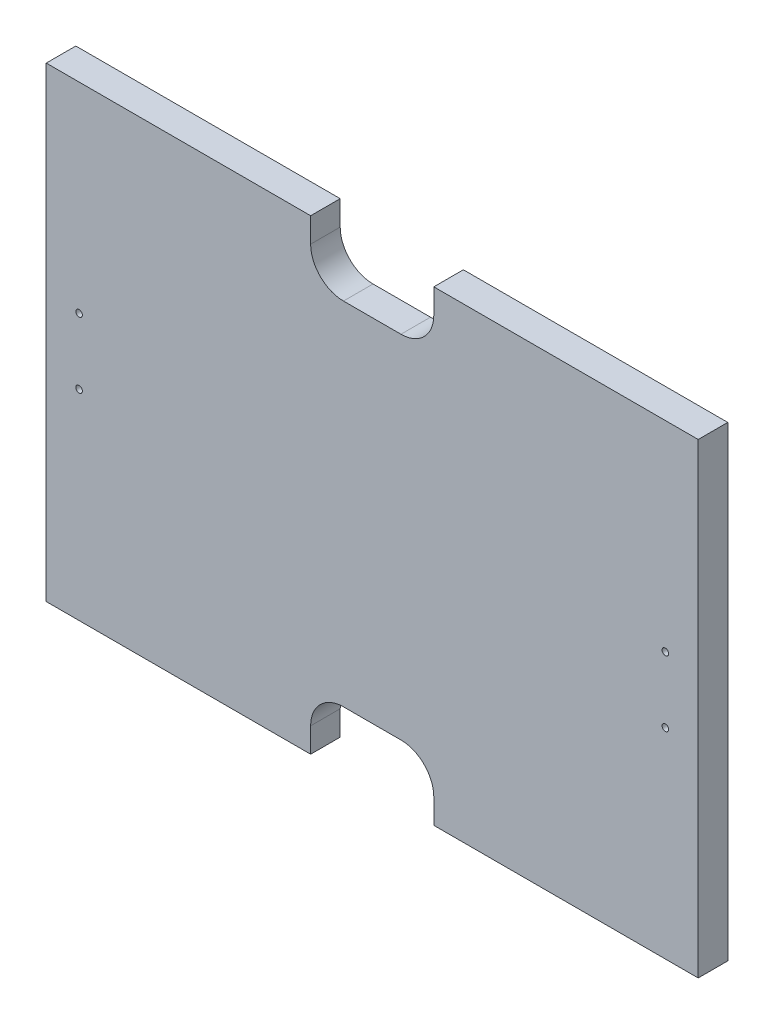
from build123d import *

# Parameters (mm, degrees)
SKETCH1_W           = 397
SKETCH1_H           = 284
BOSS_EXTRUDE1_DEPTH = 18
SKETCH2_R           = 2
CUT_EXTRUDE1_DEPTH  = 19


with BuildPart() as part:
    # Sketch1 → Boss-Extrude1 (new body)
    with BuildSketch(Plane.XY):
        with Locations((198.5, 142)):
            Rectangle(SKETCH1_W, SKETCH1_H)
    extrude(amount=BOSS_EXTRUDE1_DEPTH)

    # Sketch2 → Cut-Extrude1 (cut, through all)
    with BuildSketch(Plane.XY.offset(18)):
        with Locations((20, 162)):
            Circle(SKETCH2_R)
        with Locations((20, 122)):
            Circle(SKETCH2_R)
        with Locations((377, 122)):
            Circle(SKETCH2_R)
        with Locations((377, 162)):
            Circle(SKETCH2_R)
        with BuildLine():
            Line((236, 284), (161, 284))
            Line((161, 284), (161, 269))
            ThreePointArc((161, 269), (166.857864376, 254.857864376), (181, 249))
            Line((181, 249), (216, 249))
            ThreePointArc((216, 249), (230.142135624, 254.857864376), (236, 269))
            Line((236, 269), (236, 284))
        make_face()
        with BuildLine():
            Line((216, 35), (181, 35))
            ThreePointArc((181, 35), (166.857864376, 29.142135624), (161, 15))
            Line((161, 15), (161, 0))
            Line((161, 0), (236, 0))
            Line((236, 0), (236, 15))
            ThreePointArc((236, 15), (230.142135624, 29.142135624), (216, 35))
        make_face()
    extrude(amount=-CUT_EXTRUDE1_DEPTH, mode=Mode.SUBTRACT)


solid = part.part
